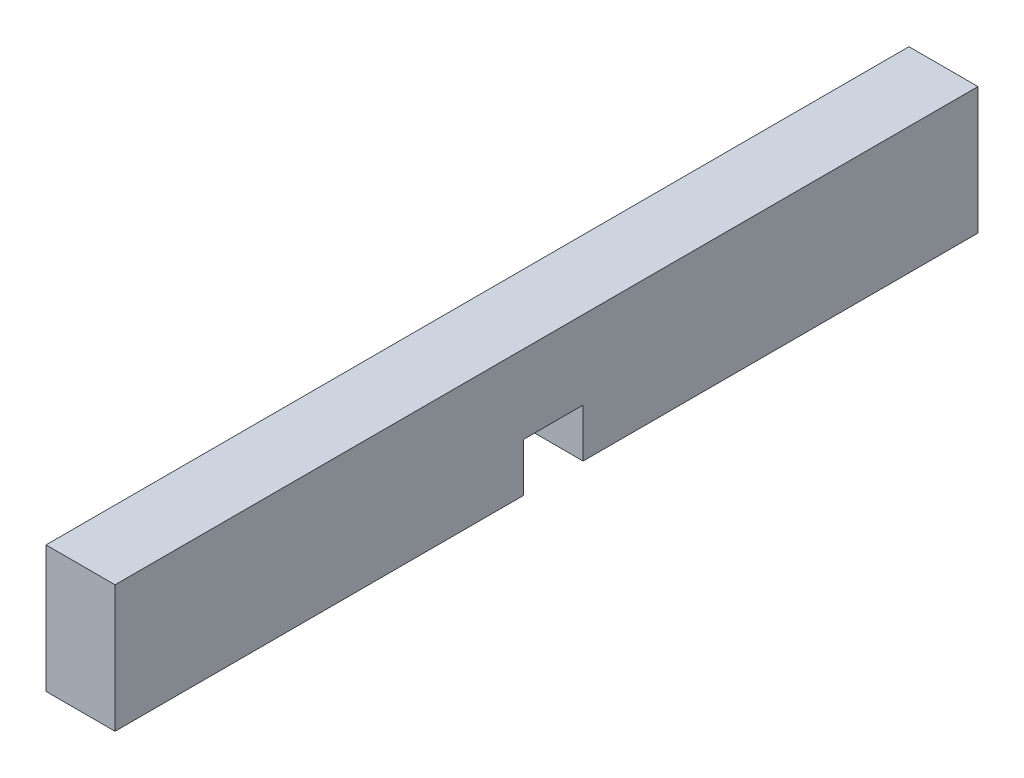
from build123d import *

# Parameters (mm, degrees)
SKETCH1_W           = 58.7248
SKETCH1_H           = 8.636
BOSS_EXTRUDE1_DEPTH = 2.3495
SKETCH2_W           = 4.064
SKETCH2_H           = 3.302
CUT_EXTRUDE1_DEPTH  = 4.699


with BuildPart() as part:
    # Sketch1 → Boss-Extrude1 (new body, symmetric)
    with BuildSketch(Plane(origin=(0, 0, 0), x_dir=(0, 0, -1), z_dir=(1, 0, 0))):
        Rectangle(SKETCH1_W, SKETCH1_H)
    extrude(amount=BOSS_EXTRUDE1_DEPTH, both=True)

    # Sketch2 → Cut-Extrude1 (cut)
    with BuildSketch(Plane(origin=(2.3495, 0, 0), x_dir=(0, 0, -1), z_dir=(1, 0, 0))):
        with Locations((0.4572, -2.667)):
            Rectangle(SKETCH2_W, SKETCH2_H)
    extrude(amount=-CUT_EXTRUDE1_DEPTH, mode=Mode.SUBTRACT)


solid = part.part
